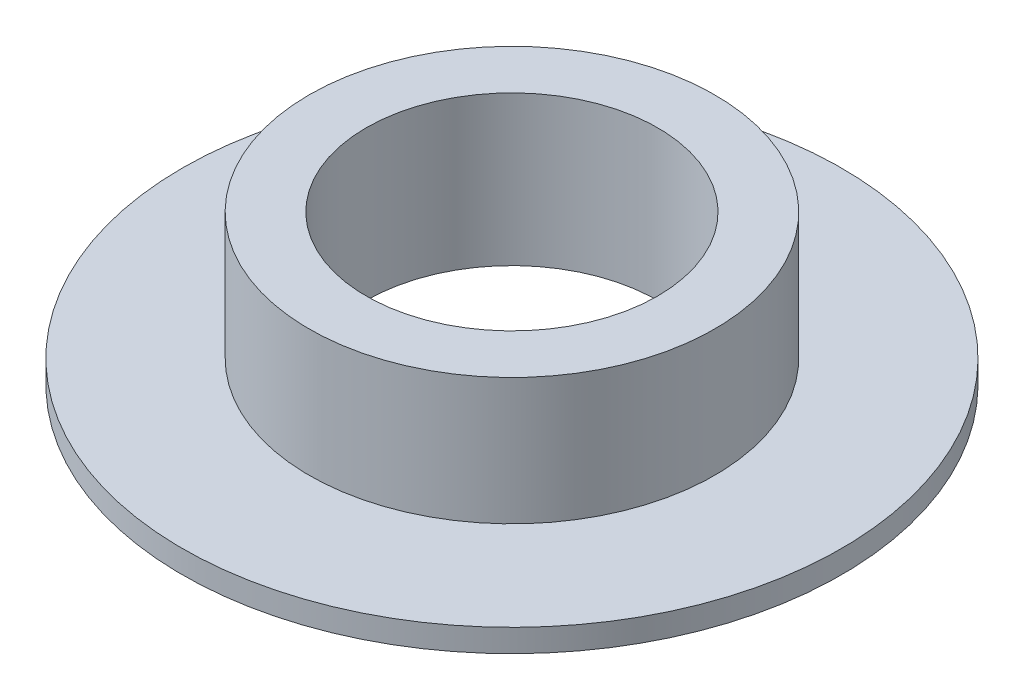
from build123d import *


with BuildPart() as part:
    # Croquis1 → Revolución1 (revolve)
    with BuildSketch(Plane.XY):
        Polygon((-51.52158728, 8.972889318), (-51.52158728, -2.827110682), (-66.02158728, -2.827110682), (-66.02158728, -1.027110682), (-56.02158728, -1.027110682), (-56.02158728, 8.972889318), align=None)
    revolve(axis=Axis((-40.02158728, 13.972889318, 0), (0, -1, 0)))


solid = part.part
